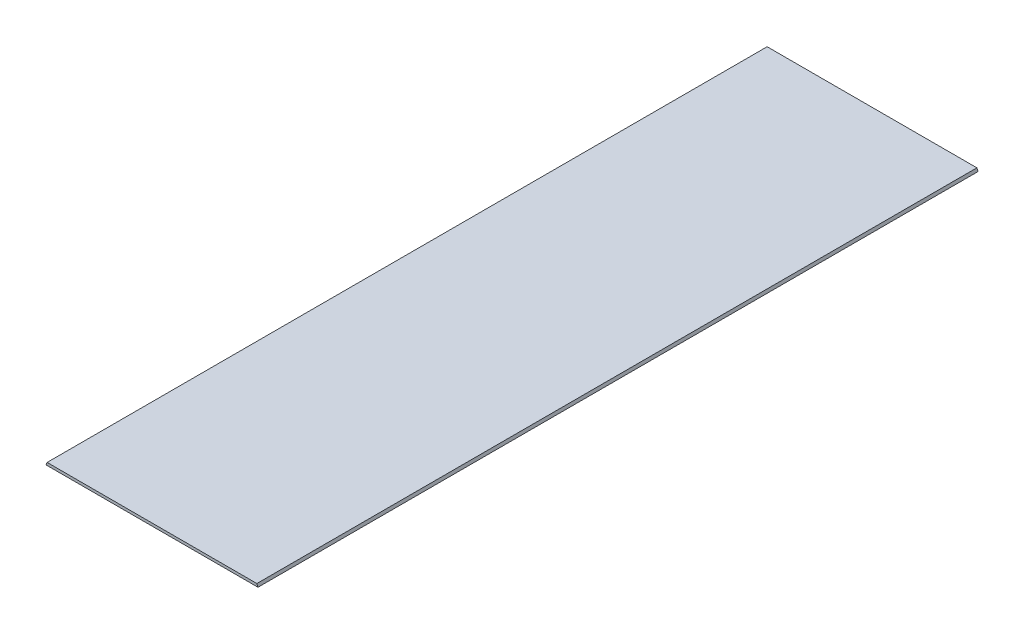
from build123d import *

# Parameters (mm, degrees)
BOSS_EXTRUDE1_DEPTH = 628.65


with BuildPart() as part:
    # Sketch1 → Boss-Extrude1 (new body)
    with BuildSketch(Plane.XY):
        Polygon((0, 0), (0.978455277, 2.3622), (184.112455277, 2.3622), (185.090910554, 0), align=None)
    extrude(amount=BOSS_EXTRUDE1_DEPTH)


solid = part.part
